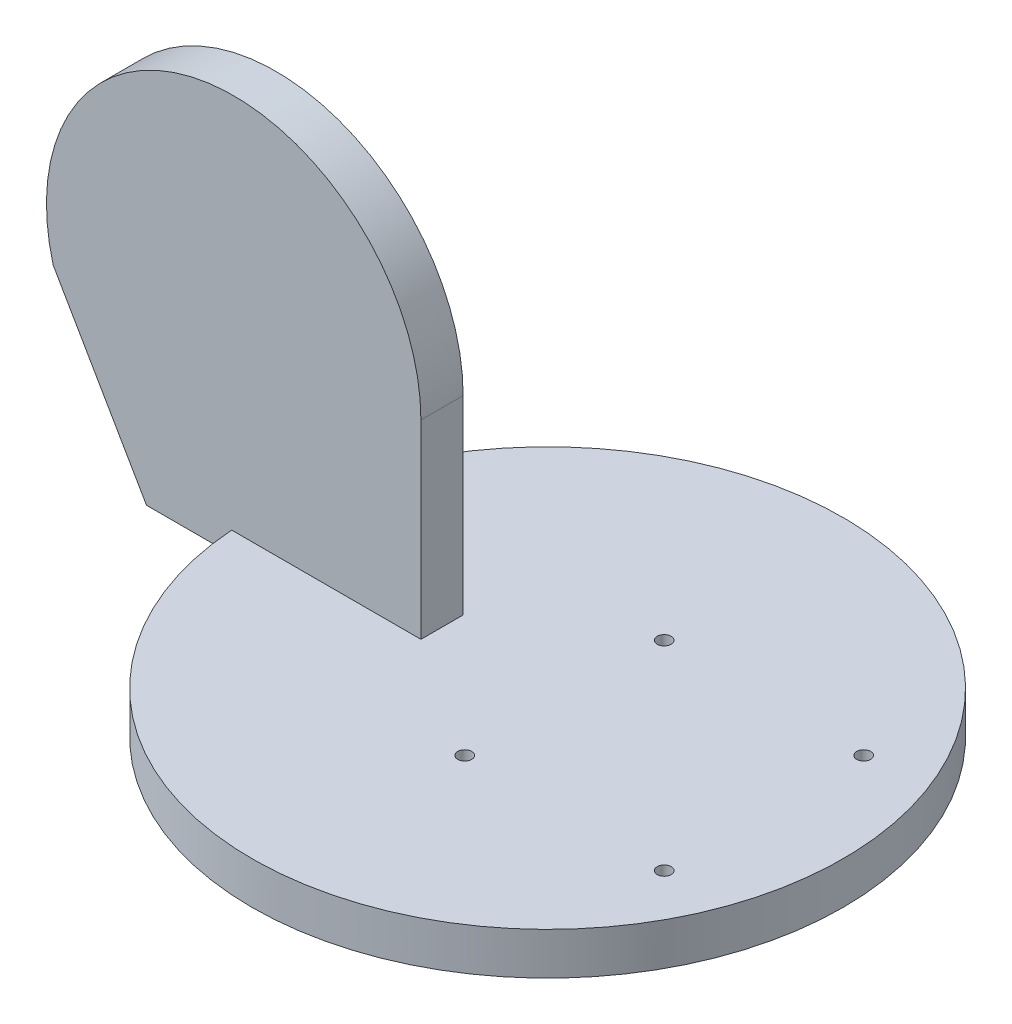
from build123d import *

# Parameters (mm, degrees)
SKETCH1_R                 = 70
BOSS_EXTRUDE1_DEPTH       = 10
SKETCH2_R                 = 65
BOSS_EXTRUDE2_DEPTH       = 3
BOSS_EXTRUDE3_DEPTH       = 5
M4X0_7_TAPPED_HOLE1_D     = 3.3
M4X0_7_TAPPED_HOLE1_DEPTH = 10.1
M4X0_7_TAPPED_HOLE1_TIP   = 0.991420021


with BuildPart() as part:
    # Sketch1 → Boss-Extrude1 (new body)
    with BuildSketch(Plane(origin=(0, 0, 0), x_dir=(1, 0, 0), z_dir=(0, 1, 0))):
        Circle(SKETCH1_R)
    extrude(amount=BOSS_EXTRUDE1_DEPTH)

    # Sketch2 → Boss-Extrude2 (add)
    with BuildSketch(Plane.XZ):
        Circle(SKETCH2_R)
    extrude(amount=BOSS_EXTRUDE2_DEPTH)

    # Sketch3 → Boss-Extrude3 (add, symmetric)
    with BuildSketch(Plane.XY):
        with BuildLine():
            Line((-25, 55), (-25, 5))
            Line((-25, 5), (-90, 5))
            Line((-90, 5), (-112.094257771, 43.204763027))
            ThreePointArc((-112.094257771, 43.204763027), (-75.29730578, 98.944673602), (-25, 55))
        make_face()
    extrude(amount=BOSS_EXTRUDE3_DEPTH, both=True)

    # M4x0.7 Tapped Hole1
    with Locations(Plane(origin=(0, 10, 0), x_dir=(1, 0, 0), z_dir=(0, 1, 0))):
        with Locations((4, 23.622), (51.244, 23.622), (51.244, -23.622), (4, -23.622)):
            Hole(M4X0_7_TAPPED_HOLE1_D / 2, depth=M4X0_7_TAPPED_HOLE1_DEPTH)
            with Locations((0, 0, -(M4X0_7_TAPPED_HOLE1_DEPTH + M4X0_7_TAPPED_HOLE1_TIP / 2))):  # 118° drill point
                Cone(0, M4X0_7_TAPPED_HOLE1_D / 2, M4X0_7_TAPPED_HOLE1_TIP, mode=Mode.SUBTRACT)


solid = part.part
